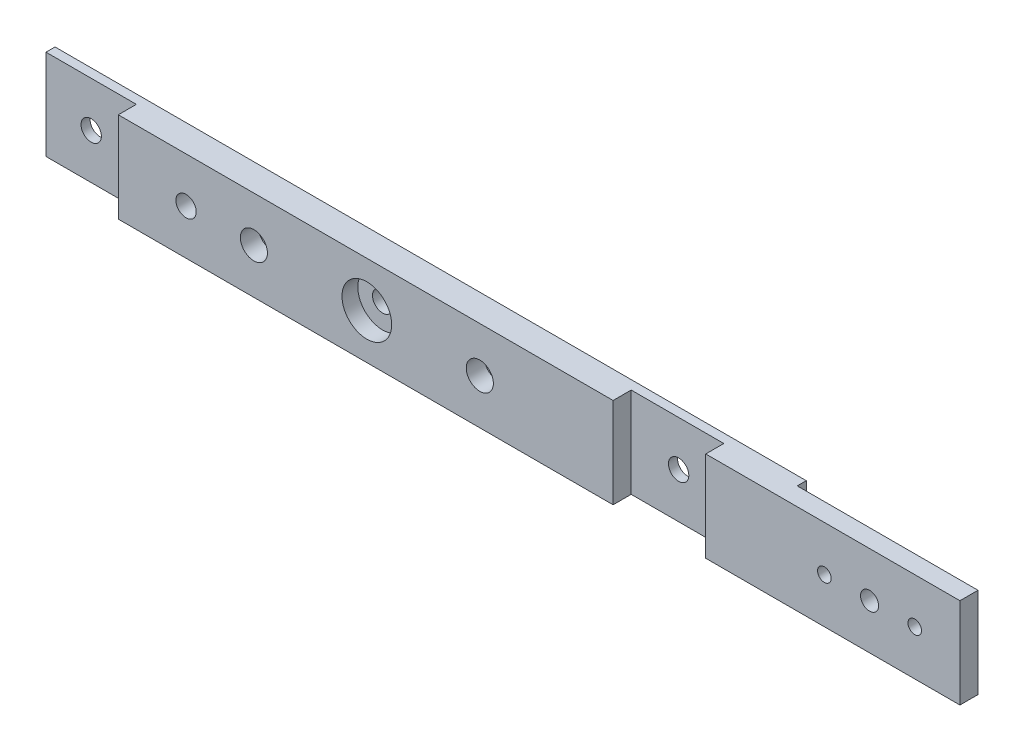
from build123d import *

# Parameters (mm, degrees)
ESQUISSE1_W             = 412.5
ESQUISSE1_H             = 40
BOSS_EXTRU_1_DEPTH      = 12
ESQUISSE2_R             = 4.5
ENL_V_MAT_EXTRU_1_DEPTH = 13
ESQUISSE3_R             = 11
ENL_V_MAT_EXTRU_2_DEPTH = 7
ESQUISSE4_W             = 40
ESQUISSE4_H             = 40
ESQUISSE4_W_2           = 41
ENL_V_MAT_EXTRU_3_DEPTH = 8
ESQUISSE5_R             = 6
ENL_V_MAT_EXTRU_5_DEPTH = 8
ESQUISSE6_W             = 80
ESQUISSE6_H             = 40
ENL_V_MAT_EXTRU_6_DEPTH = 4
ESQUISSE7_R             = 3
ENL_V_MAT_EXTRU_7_DEPTH = 9
ESQUISSE8_R             = 4
ENL_V_MAT_EXTRU_8_DEPTH = 9
ESQUISSE9_R             = 4.5
ENL_V_MAT_EXTRU_9_DEPTH = 6


with BuildPart() as part:
    # Esquisse1 → Boss.-Extru.1 (new body)
    with BuildSketch(Plane.XY):
        with Locations((-20.839929175, 36.964793741)):
            Rectangle(ESQUISSE1_W, ESQUISSE1_H)
    extrude(amount=BOSS_EXTRU_1_DEPTH)

    # Esquisse2 → Enlèv. mat.-Extru.1 (cut, through all)
    with BuildSketch(Plane.XY.offset(12)):
        with Locations((-207.089929175, 36.964793741)):
            Circle(ESQUISSE2_R)
        with Locations((-157.089929175, 36.964793741)):
            Circle(ESQUISSE2_R)
        with Locations((52.910070825, 36.964793741)):
            Circle(ESQUISSE2_R)
    extrude(amount=-ENL_V_MAT_EXTRU_1_DEPTH, mode=Mode.SUBTRACT)

    # Esquisse3 → Enlèv. mat.-Extru.2 (cut)
    with BuildSketch(Plane.XY.offset(12)):
        with Locations((-77.089929175, 36.964793741)):
            Circle(ESQUISSE3_R)
    extrude(amount=-ENL_V_MAT_EXTRU_2_DEPTH, mode=Mode.SUBTRACT)

    # Esquisse4 → Enlèv. mat.-Extru.3 (cut)
    with BuildSketch(Plane.XY.offset(12)):
        with Locations((-207.089929175, 36.964793741)):
            Rectangle(ESQUISSE4_W, ESQUISSE4_H)
        with Locations((52.410070825, 36.964793741)):
            Rectangle(ESQUISSE4_W_2, ESQUISSE4_H)
    extrude(amount=-ENL_V_MAT_EXTRU_3_DEPTH, mode=Mode.SUBTRACT)

    # Esquisse5 → Enlèv. mat.-Extru.5 (cut)
    with BuildSketch(Plane.XY.offset(12)):
        with Locations((-127.089929175, 36.964793741)):
            Circle(ESQUISSE5_R)
        with Locations((-27.089929175, 36.964793741)):
            Circle(ESQUISSE5_R)
    extrude(amount=-ENL_V_MAT_EXTRU_5_DEPTH, mode=Mode.SUBTRACT)

    # Esquisse6 → Enlèv. mat.-Extru.6 (cut)
    with BuildSketch(Plane(origin=(0, 0, 0), x_dir=(-1, 0, 0), z_dir=(0, 0, -1))):
        with Locations((-145.410070825, 36.964793741)):
            Rectangle(ESQUISSE6_W, ESQUISSE6_H)
    extrude(amount=-ENL_V_MAT_EXTRU_6_DEPTH, mode=Mode.SUBTRACT)

    # Esquisse7 → Enlèv. mat.-Extru.7 (cut, through all)
    with BuildSketch(Plane(origin=(0, 0, 4), x_dir=(-1, 0, 0), z_dir=(0, 0, -1))):
        with Locations((-165.410070825, 36.964793741)):
            Circle(ESQUISSE7_R)
        with Locations((-125.410070825, 36.964793741)):
            Circle(ESQUISSE7_R)
    extrude(amount=-ENL_V_MAT_EXTRU_7_DEPTH, mode=Mode.SUBTRACT)

    # Esquisse8 → Enlèv. mat.-Extru.8 (cut, through all)
    with BuildSketch(Plane(origin=(0, 0, 4), x_dir=(-1, 0, 0), z_dir=(0, 0, -1))):
        with Locations((-145.410070825, 36.964793741)):
            Circle(ESQUISSE8_R)
    extrude(amount=-ENL_V_MAT_EXTRU_8_DEPTH, mode=Mode.SUBTRACT)

    # Esquisse9 → Enlèv. mat.-Extru.9 (cut, through all)
    with BuildSketch(Plane.XY.offset(5)):
        with Locations((-77.089929175, 36.964793741)):
            Circle(ESQUISSE9_R)
    extrude(amount=-ENL_V_MAT_EXTRU_9_DEPTH, mode=Mode.SUBTRACT)


solid = part.part
